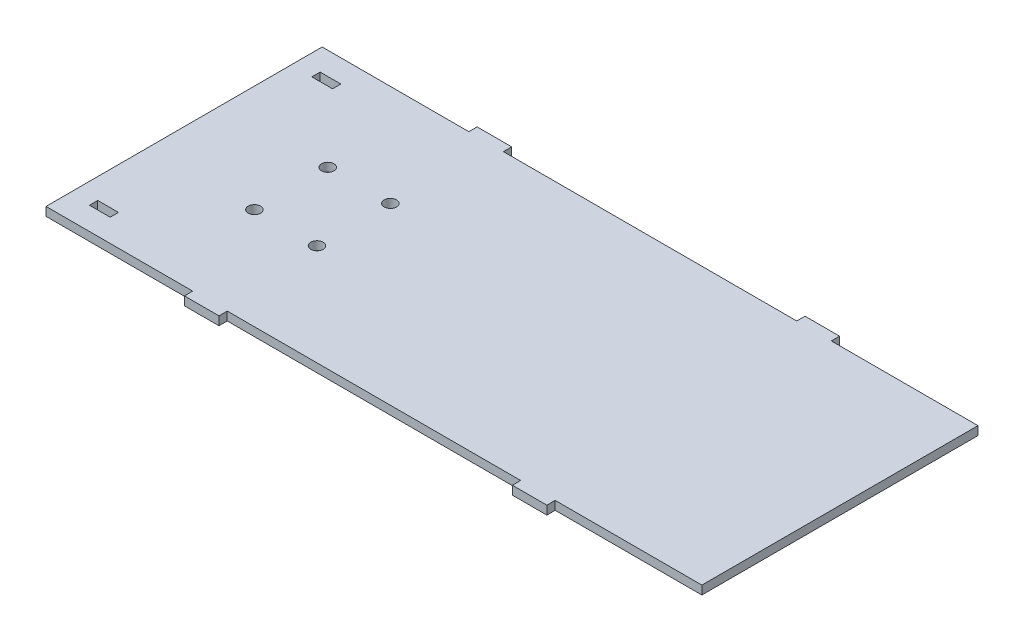
from build123d import *

# Parameters (mm, degrees)
MAIN_FRAME_DEPTH   = 3.175
SKETCH2_R          = 2.276969522
FRONT_WHEEL_DEPTH  = 4.175
SKETCH4_W          = 7.62
SKETCH4_H          = 3.048
SENSOR_HOLES_DEPTH = 4.175


with BuildPart() as part:
    # Sketch1 → Main Frame (new body)
    with BuildSketch(Plane(origin=(0, 0, 0), x_dir=(1, 0, 0), z_dir=(0, 1, 0))):
        Polygon((0, 0), (41.275, 0), (41.275, -3.048), (53.975, -3.048), (53.975, 0), (161.925, 0), (161.925, -3.048), (174.625, -3.048), (174.625, 0), (228.6, 0), (228.6, 101.6), (174.625, 101.6), (174.625, 104.648), (161.925, 104.648), (161.925, 101.6), (53.975, 101.6), (53.975, 104.648), (41.275, 104.648), (41.275, 101.6), (0, 101.6), (-12.7, 101.6), (-12.7, 0), align=None)
    extrude(amount=MAIN_FRAME_DEPTH)

    # Sketch2 → Front Wheel (cut, through all)
    with BuildSketch(Plane(origin=(0, 3.175, 0), x_dir=(1, 0, 0), z_dir=(0, 1, 0))):
        with Locations((26.67, 64.29375)):
            Circle(SKETCH2_R)
        with Locations((49.68875, 64.29375)):
            Circle(SKETCH2_R)
        with Locations((49.68875, 37.30625)):
            Circle(SKETCH2_R)
        with Locations((26.67, 37.30625)):
            Circle(SKETCH2_R)
    extrude(amount=-FRONT_WHEEL_DEPTH, mode=Mode.SUBTRACT)

    # Sketch4 → Sensor Holes (cut, through all)
    with BuildSketch(Plane(origin=(0, 3.175, 0), x_dir=(1, 0, 0), z_dir=(0, 1, 0))):
        with Locations((-1.27, 91.707882035)):
            Rectangle(SKETCH4_W, SKETCH4_H)
        with Locations((-1.27, 9.892117965)):
            Rectangle(SKETCH4_W, SKETCH4_H)
    extrude(amount=-SENSOR_HOLES_DEPTH, mode=Mode.SUBTRACT)


solid = part.part
